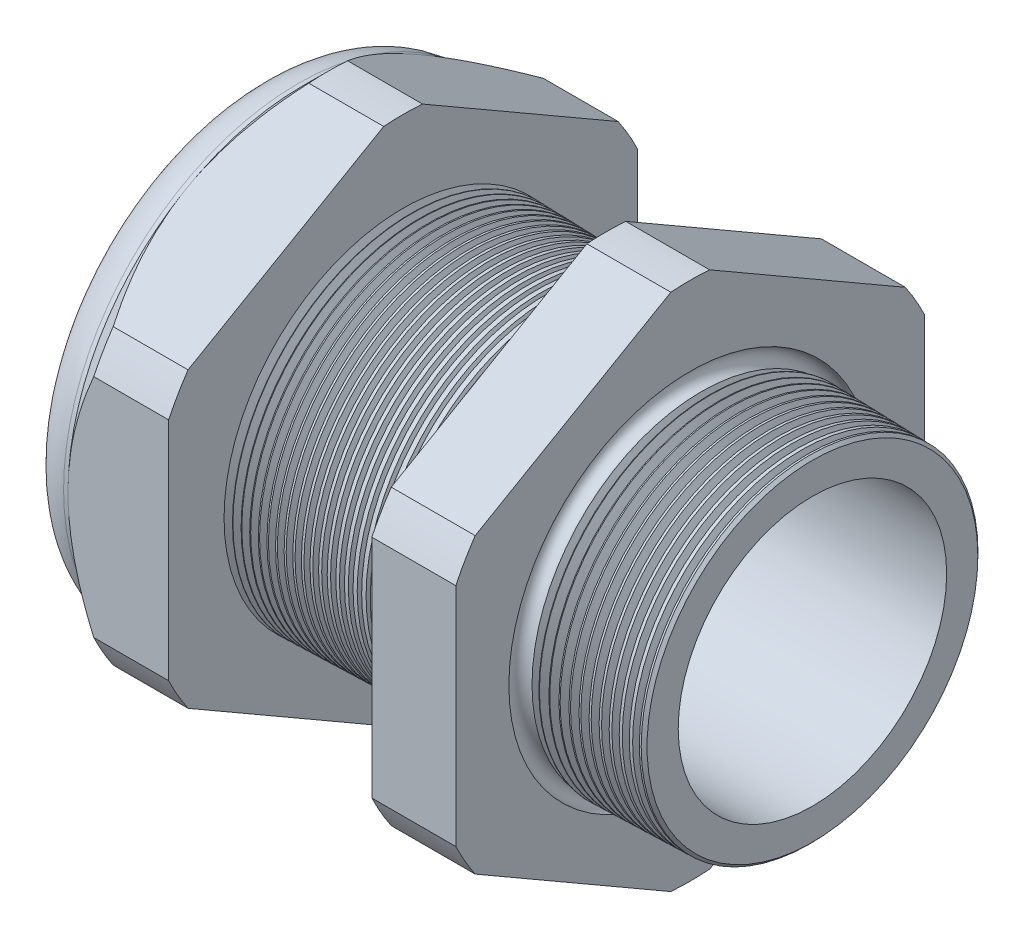
from build123d import *

# Parameters (mm, degrees)
SKETCH12_OUTSIDE_W = 111.534
SKETCH12_OUTSIDE_H = 111.534
CUT_EXTRUDE2_DEPTH = 46.584
FILLET4_R          = 3.81
SKETCH19_OUTSIDE_W = 67.904
SKETCH19_OUTSIDE_H = 72.514
SKETCH19_OUTSIDE_R = 20.955
CUT_EXTRUDE3_DEPTH = 3.99796
CUT_EXTRUDE3_DRAFT = -45
CHAMFER1_SIZE      = 0.260919487
CHAMFER1_SIZE2     = 0.254
SKETCH21_R         = 12.446
PLUG_DEPTH         = 12.7
SKETCH22_R         = 12.192
CUT_EXTRUDE4_DEPTH = 0.508
SKETCH27_R         = 4.699
PLUGHOLES_DEPTH    = 50.276
CIRPATTERN1_COUNT  = 4
LPATTERN1_COUNT    = 24
LPATTERN1_PITCH    = 0.762
LPATTERN2_COUNT    = 12
LPATTERN2_PITCH    = 0.889
SKETCH32_R         = 0.889


with BuildPart() as part:
    # Sketch10 → Revolve2 (revolve)
    with BuildSketch(Plane.XY, mode=Mode.PRIVATE) as revolve2_sk:
        Polygon((-46.736, 12.446), (-33.536, 12.446), (3.048, 11.996014245), (3.048, 15.044014245), (-7.874, 15.330016881), (-7.874, 41.91), (-15.374, 41.91), (-15.374, 15.526411292), (-33.536, 16.002), (-33.536, 41.91), (-42.536, 41.91), (-42.536, 20.955), (-46.736, 20.955), align=None)
    revolve(revolve2_sk.sketch.rotate(Axis((0, 0, 0), (-1, 0, 0)), 90), axis=Axis((0, 0, 0), (-1, 0, 0)))  # turned: the seam where the file's is

    # Sketch12 outside → Cut-Extrude2 (cut, through all)
    with BuildSketch(Plane.ZY.offset(42.536)):
        Rectangle(SKETCH12_OUTSIDE_W, SKETCH12_OUTSIDE_H)
        with BuildLine():
            Line((-1.734592832, 23.195282143), (-19.220407168, 13.099842529))
            ThreePointArc((-19.220407168, 13.099842529), (-20.143794193, 11.630025), (-20.955, 10.095439614))
            Line((-20.955, 10.095439614), (-20.955, -10.095439614))
            ThreePointArc((-20.955, -10.095439614), (-20.143794193, -11.630025), (-19.220407168, -13.099842529))
            Line((-19.220407168, -13.099842529), (-1.734592832, -23.195282143))
            ThreePointArc((-1.734592832, -23.195282143), (0, -23.26005), (1.734592832, -23.195282143))
            Line((1.734592832, -23.195282143), (19.220407168, -13.099842529))
            ThreePointArc((19.220407168, -13.099842529), (20.143794193, -11.630025), (20.955, -10.095439614))
            Line((20.955, -10.095439614), (20.955, 10.095439614))
            ThreePointArc((20.955, 10.095439614), (20.143794193, 11.630025), (19.220407168, 13.099842529))
            Line((19.220407168, 13.099842529), (1.734592832, 23.195282143))
            ThreePointArc((1.734592832, 23.195282143), (0, 23.26005), (-1.734592832, 23.195282143))
        make_face(mode=Mode.SUBTRACT)
    extrude(amount=-CUT_EXTRUDE2_DEPTH, mode=Mode.SUBTRACT)

    # Fillet4
    fillet4_edges = [part.edges().sort_by_distance(p)[0] for p in [
        (-46.736, 0, 20.955),
    ]]
    fillet(fillet4_edges, radius=FILLET4_R)


with BuildPart() as cut_extrude3_tool:
    # Sketch19 outside → Cut-Extrude3 (with draft: the straight prism first)
    with BuildSketch(Plane.ZY.offset(42.536)):
        Rectangle(SKETCH19_OUTSIDE_W, SKETCH19_OUTSIDE_H)
        Circle(SKETCH19_OUTSIDE_R, mode=Mode.SUBTRACT)
    extrude(amount=-CUT_EXTRUDE3_DEPTH)
    # Cut-Extrude3: the draft: its side faces are tilted about the plane it starts from
    cut_extrude3_sides = [cut_extrude3_tool.faces().sort_by_distance(p)[0] for p in [
        (-40.53702, -36.257, 0),
        (-40.53702, 0, 33.952),
        (-40.53702, 36.257, 0),
        (-40.53702, 0, -33.952),
        (-40.53702, 0, -20.955),
    ]]
    draft(cut_extrude3_sides, Plane.ZY.offset(42.536), CUT_EXTRUDE3_DRAFT)


with BuildPart() as part_1:
    add(part.part)

    # Cut-Extrude3: cut by cut_extrude3_tool
    add(cut_extrude3_tool.part, mode=Mode.SUBTRACT)

    # Chamfer1
    chamfer1_edges = [part_1.edges().sort_by_distance(p)[0] for p in [
        (3.048, 0, 15.044014245),
    ]]
    chamfer1_side = [part_1.faces().sort_by_distance(p)[0] for p in [
        (3.048, 0, 12.421523225),
    ]]
    chamfer(chamfer1_edges, length=CHAMFER1_SIZE, length2=CHAMFER1_SIZE2, reference=chamfer1_side[0])

    # Sketch29 → Cut-Revolve1 (revolve, cut)
    with BuildSketch(Plane.XY, mode=Mode.PRIVATE) as cut_revolve1_sk:
        Polygon((-33.536, 16.002), (-32.803016419, 15.982806149), (-33.186130572, 15.357620673), align=None)
    cut_revolve1 = revolve(cut_revolve1_sk.sketch.rotate(Axis((0, 0, 0), (-1, 0, 0)), 90), axis=Axis((0, 0, 0), (-1, 0, 0)), mode=Mode.SUBTRACT)  # turned: the seam where the file's is

    # LPattern1: Cut-Revolve1 ×24
    with Locations(*[(i * LPATTERN1_PITCH, 0, 0) for i in range(1, LPATTERN1_COUNT)]):
        add(cut_revolve1, mode=Mode.SUBTRACT)

    # Sketch30 → Cut-Revolve2 (revolve, cut)
    with BuildSketch(Plane.XY, mode=Mode.PRIVATE) as cut_revolve2_sk:
        Polygon((-7.874, 15.330016881), (-6.994419703, 15.30698426), (-7.454156686, 14.556761689), align=None)
    cut_revolve2 = revolve(cut_revolve2_sk.sketch.rotate(Axis((0, 0, 0), (-1, 0, 0)), 270), axis=Axis((0, 0, 0), (-1, 0, 0)), mode=Mode.SUBTRACT)  # turned: the seam where the file's is

    # LPattern2: Cut-Revolve2 ×12
    with Locations(*[(i * LPATTERN2_PITCH, 0, 0) for i in range(1, LPATTERN2_COUNT)]):
        add(cut_revolve2, mode=Mode.SUBTRACT)

    # Sketch32 → Cut-Revolve3 (revolve, cut)
    with BuildSketch(Plane.XY, mode=Mode.PRIVATE) as cut_revolve3_sk:
        with Locations((-7.747, 15.330016881)):
            Circle(SKETCH32_R)
    revolve(cut_revolve3_sk.sketch.rotate(Axis((0, 0, 0), (-1, 0, 0)), 270), axis=Axis((0, 0, 0), (-1, 0, 0)), mode=Mode.SUBTRACT)  # turned: the seam where the file's is


with BuildPart() as body_2:
    # Sketch21 → plug (new body)
    with BuildSketch(Plane.ZY.offset(46.736)):
        Circle(SKETCH21_R)
    extrude(amount=-PLUG_DEPTH)

    # Sketch22 → Cut-Extrude4 (cut)
    with BuildSketch(Plane.ZY.offset(46.736)):
        Circle(SKETCH22_R)
    extrude(amount=-CUT_EXTRUDE4_DEPTH, mode=Mode.SUBTRACT)

    # Sketch27 → plugholes (cut, through all)
    with BuildSketch(Plane.ZY.offset(46.228)):
        with Locations((-7.474204, 0)):
            Circle(SKETCH27_R)
    plugholes = extrude(amount=-PLUGHOLES_DEPTH, mode=Mode.SUBTRACT)

    # CirPattern1: plugholes ×4 about axis
    cirpattern1_axis = Axis((0, 0, 0), (1, 0, 0))
    for i in range(1, CIRPATTERN1_COUNT):
        add(plugholes.rotate(cirpattern1_axis, i * 360 / CIRPATTERN1_COUNT), mode=Mode.SUBTRACT)


solid = Compound([part_1.part, body_2.part])
